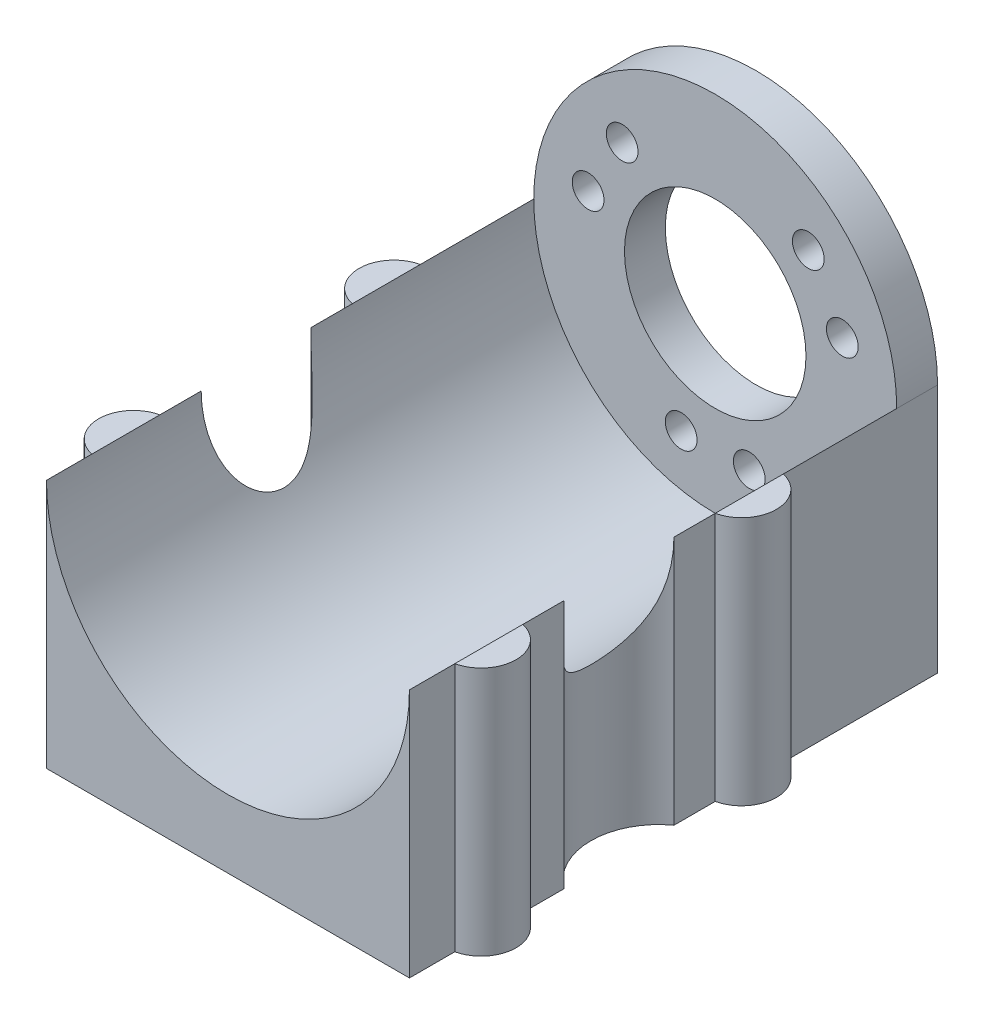
from build123d import *

# Parameters (mm, degrees)
SKETCH3_W           = 40
SKETCH3_H           = 53.7
BOSS_EXTRUDE1_DEPTH = 27.5
BOSS_EXTRUDE4_DEPTH = 27.5
CUT_EXTRUDE1_DEPTH  = 28.5
SKETCH7_R           = 20
CUT_EXTRUDE2_DEPTH  = 54.7
BOSS_EXTRUDE5_DEPTH = 4.5
SKETCH9_R           = 10
CUT_EXTRUDE3_DEPTH  = 59.2000001
SKETCH10_R          = 1.75
CUT_EXTRUDE4_DEPTH  = 59.2000001


with BuildPart() as part:
    # Sketch3 → Boss-Extrude1 (new body)
    with BuildSketch(Plane(origin=(0, 0, 0), x_dir=(1, 0, 0), z_dir=(0, 1, 0))):
        with Locations((20, 26.85)):
            Rectangle(SKETCH3_W, SKETCH3_H)
    extrude(amount=BOSS_EXTRUDE1_DEPTH)

    # Sketch4 → Boss-Extrude4 (add)
    with BuildSketch(Plane(origin=(0, 27.5, 0), x_dir=(1, 0, 0), z_dir=(0, 1, 0))):
        with BuildLine():
            Line((0, 41.2), (0, 33.7))
            ThreePointArc((0, 33.7), (-2.999999474, 37.45), (0, 41.2))
        make_face()
        with BuildLine():
            Line((0, 12.5), (0, 5))
            ThreePointArc((0, 5), (-2.999999474, 8.75), (0, 12.5))
        make_face()
        with BuildLine():
            Line((40, 41.2), (40, 33.7))
            ThreePointArc((40, 33.7), (42.999999474, 37.45), (40, 41.2))
        make_face()
        with BuildLine():
            Line((40, 12.5), (40, 5))
            ThreePointArc((40, 5), (42.999999474, 8.75), (40, 12.5))
        make_face()
    extrude(amount=-BOSS_EXTRUDE4_DEPTH)

    # Sketch6 → Cut-Extrude1 (cut, through all)
    with BuildSketch(Plane(origin=(0, 27.5, 0), x_dir=(1, 0, 0), z_dir=(0, 1, 0))):
        with BuildLine():
            Line((0, 29.15), (0, 17.05))
            ThreePointArc((0, 17.05), (3.100001365, 23.1), (0, 29.15))
        make_face()
        with BuildLine():
            Line((40, 29.15), (40, 17.05))
            ThreePointArc((40, 17.05), (36.899998635, 23.1), (40, 29.15))
        make_face()
    extrude(amount=-CUT_EXTRUDE1_DEPTH, mode=Mode.SUBTRACT)

    # Sketch7 → Cut-Extrude2 (cut, through all)
    with BuildSketch(Plane(origin=(0, 0, -53.7), x_dir=(-1, 0, 0), z_dir=(0, 0, -1))):
        with Locations((-20, 27.5)):
            Circle(SKETCH7_R)
    extrude(amount=-CUT_EXTRUDE2_DEPTH, mode=Mode.SUBTRACT)

    # Sketch8 → Boss-Extrude5 (add)
    with BuildSketch(Plane(origin=(0, 0, -53.7), x_dir=(-1, 0, 0), z_dir=(0, 0, -1))):
        with BuildLine():
            Line((-40, 27.5), (-40, 0))
            Line((-40, 0), (0, 0))
            Line((0, 0), (0, 27.5))
            ThreePointArc((0, 27.5), (-20, 47.5), (-40, 27.5))
        make_face()
    extrude(amount=BOSS_EXTRUDE5_DEPTH)

    # Sketch9 → Cut-Extrude3 (cut, through all)
    with BuildSketch(Plane(origin=(0, 0, -58.2), x_dir=(-1, 0, 0), z_dir=(0, 0, -1))):
        with Locations((-20, 27.5)):
            Circle(SKETCH9_R)
    extrude(amount=-CUT_EXTRUDE3_DEPTH, mode=Mode.SUBTRACT)

    # Sketch10 → Cut-Extrude4 (cut, through all)
    with BuildSketch(Plane(origin=(0, 0, -58.2), x_dir=(-1, 0, 0), z_dir=(0, 0, -1))):
        with Locations((-23.75, 13.493305172)):
            Circle(SKETCH10_R)
        with Locations((-16.25, 13.493305172)):
            Circle(SKETCH10_R)
        with Locations((-34.005153544, 31.25575215)):
            Circle(SKETCH10_R)
        with Locations((-30.255153544, 37.750942678)):
            Circle(SKETCH10_R)
        with Locations((-9.744846456, 37.750942678)):
            Circle(SKETCH10_R)
        with Locations((-5.994846456, 31.25575215)):
            Circle(SKETCH10_R)
    extrude(amount=-CUT_EXTRUDE4_DEPTH, mode=Mode.SUBTRACT)


solid = part.part
